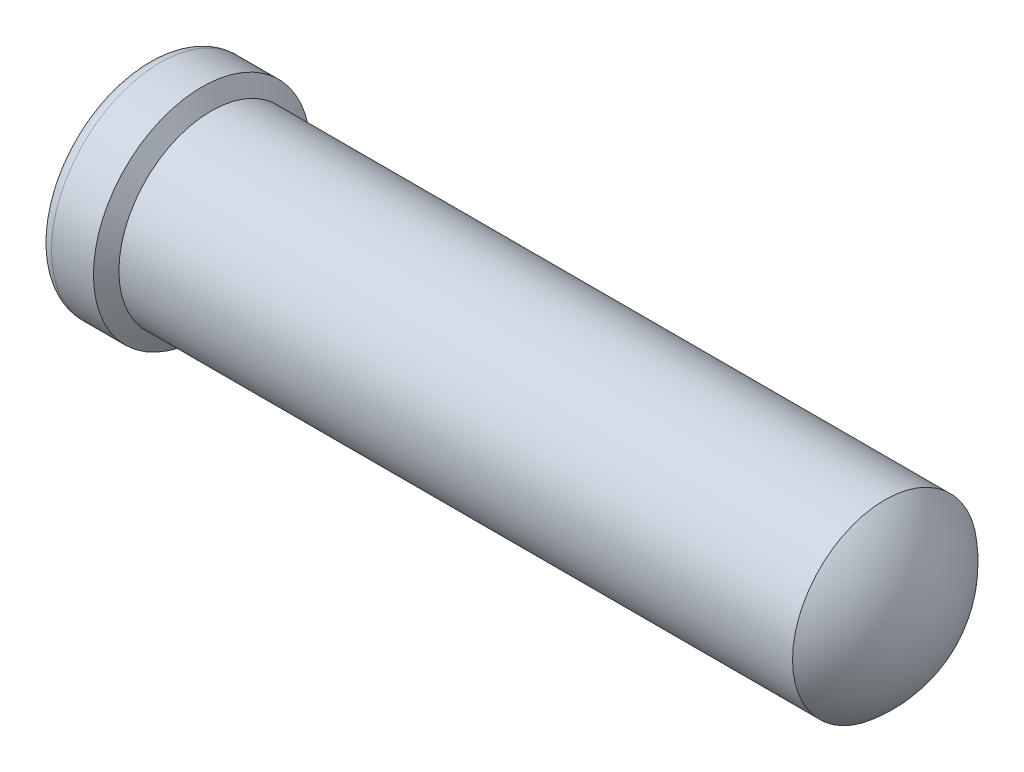
from build123d import *

# Parameters (mm, degrees)
HOLE2_D           = 0.9144
HOLE2_DEPTH       = 1.9304
HOLE2_CSINK_D     = 1.0922
HOLE2_CSINK_ANGLE = 90
HOLE2_TIP         = 0.274713475


with BuildPart() as part:
    # Sketch1 → RevolutionAngle1 (revolve)
    with BuildSketch(Plane.XY):
        with BuildLine():
            Line((0, 0), (0, 0.54737))
            ThreePointArc((0, 0.54737), (0.022318463, 0.601251537), (0.0762, 0.62357))
            Line((0.0762, 0.62357), (0.3175, 0.62357))
            Line((0.3175, 0.62357), (0.371026143, 0.53086))
            Line((0.371026143, 0.53086), (4.2418, 0.53086))
            ThreePointArc((4.2418, 0.53086), (4.42628421, 0.292934407), (4.4958, 0))
            Line((4.4958, 0), (0, 0))
        make_face()
    revolve(axis=Axis((0, 0, 0), (1, 0, 0)))

    # Hole2
    with Locations(Plane(origin=(0, 0, 0), x_dir=(0, -1, 0), z_dir=(-1, 0, 0))):
        with Locations((0, 0)):
            CounterSinkHole(HOLE2_D / 2, HOLE2_CSINK_D / 2, depth=HOLE2_DEPTH, counter_sink_angle=HOLE2_CSINK_ANGLE)
            with Locations((0, 0, -(HOLE2_DEPTH + HOLE2_TIP / 2))):  # 118° drill point
                Cone(0, HOLE2_D / 2, HOLE2_TIP, mode=Mode.SUBTRACT)


solid = part.part
